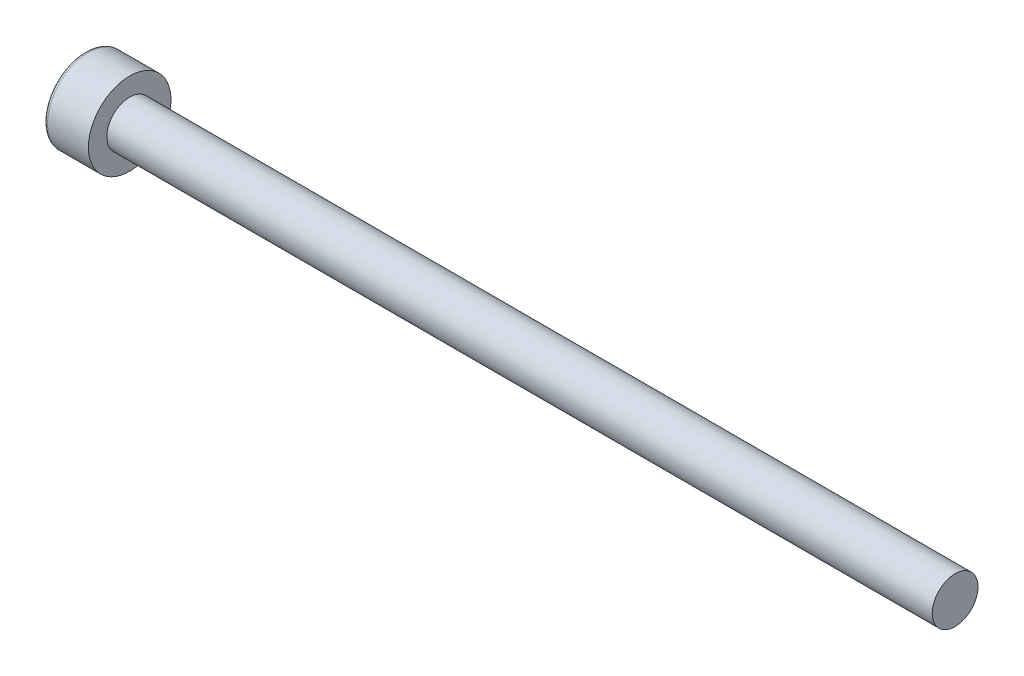
from build123d import *

# Parameters (mm, degrees)
CUT_EXTRUDE_1_DEPTH = 1.1
FILLET_1_R          = 0.2


with BuildPart() as part:
    # 草图1 → 旋转1 (revolve)
    with BuildSketch(Plane.XY):
        Polygon((0, 0), (0, 2.25), (2.43, 2.25), (2.43, 1.25), (47.43, 1.25), (47.43, 0), align=None)
    revolve(axis=Axis((0, 0, 0), (1, 0, 0)))

    # 草图2 → 切除-拉伸1 (cut)
    with BuildSketch(Plane.ZY):
        Polygon((-1.154700538, 0), (-0.577350269, -1), (0.577350269, -1), (1.154700538, 0), (0.577350269, 1), (-0.577350269, 1), align=None)
    extrude(amount=-CUT_EXTRUDE_1_DEPTH, mode=Mode.SUBTRACT)

    # 圆角1
    fillet_1_edges = [part.edges().sort_by_distance(p)[0] for p in [
        (0, -2.25, 0),
    ]]
    fillet(fillet_1_edges, radius=FILLET_1_R)


solid = part.part
